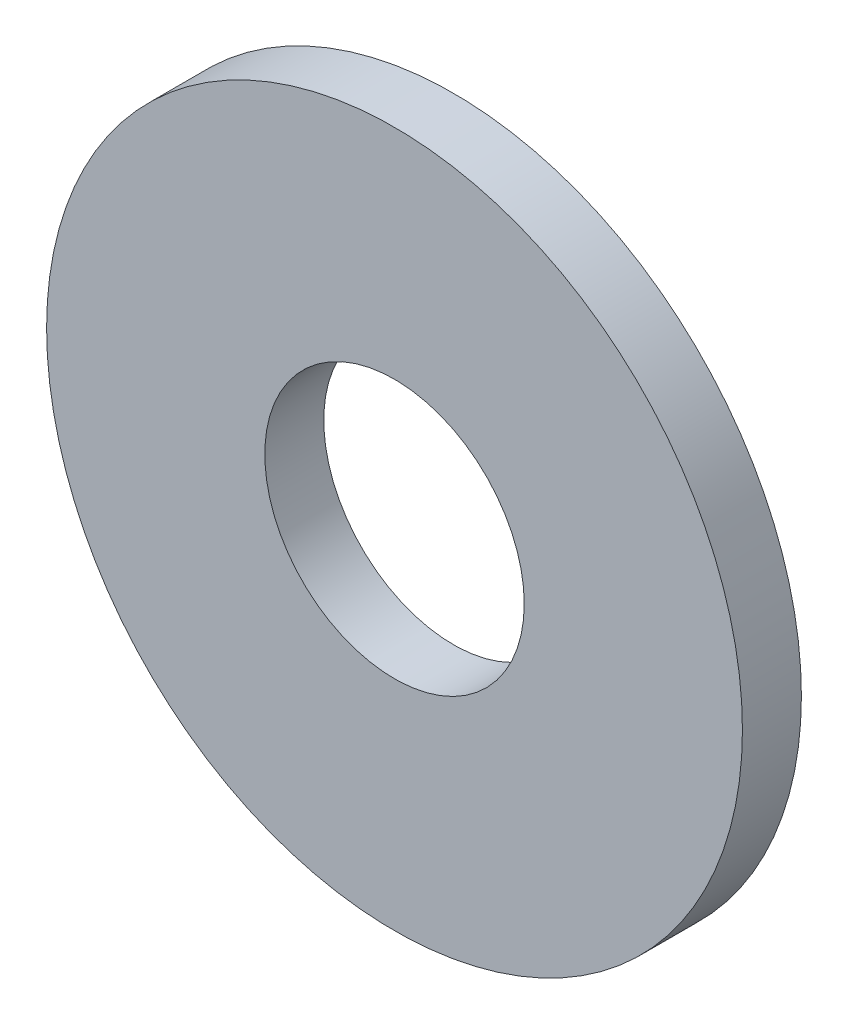
from build123d import *

# Parameters (mm, degrees)
SKETCH3_R           = 5.9
SKETCH3_R_2         = 2.2
BOSS_EXTRUDE1_DEPTH = 0.5


with BuildPart() as part:
    # Sketch3 → Boss-Extrude1 (new body, symmetric)
    with BuildSketch(Plane.XY):
        Circle(SKETCH3_R)
        Circle(SKETCH3_R_2, mode=Mode.SUBTRACT)
    extrude(amount=BOSS_EXTRUDE1_DEPTH, both=True)


solid = part.part
